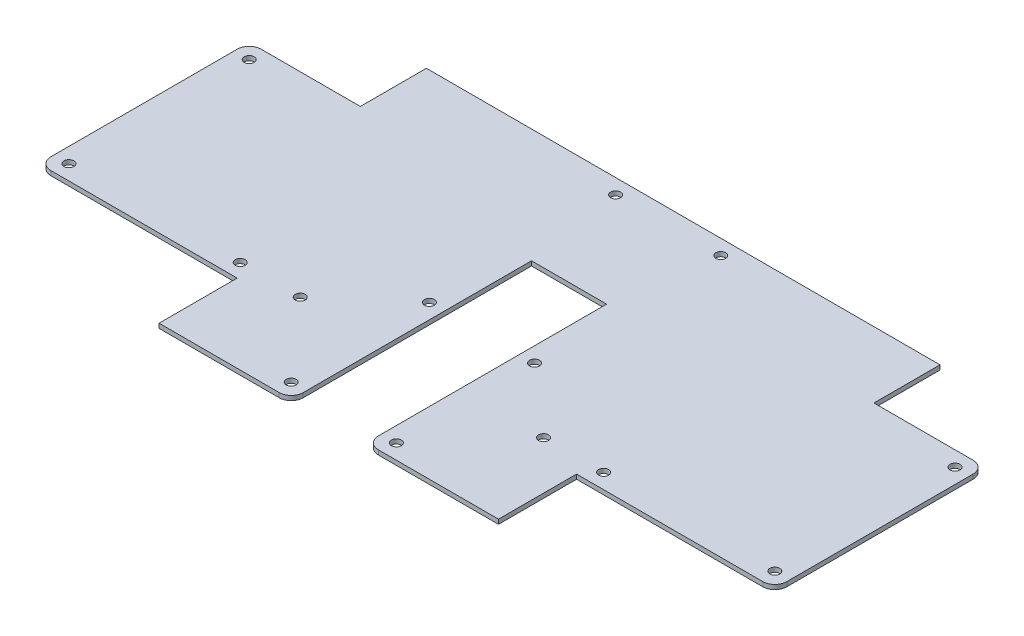
from build123d import *

# Parameters (mm, degrees)
SKETCH1_W           = 245
SKETCH1_H           = 118
BOSS_EXTRUDE1_DEPTH = 1.5
SKETCH2_W           = 37
SKETCH2_H           = 22
SKETCH2_W_2         = 66
SKETCH2_H_2         = 26
SKETCH2_W_3         = 25
SKETCH2_H_3         = 80
CUT_EXTRUDE1_DEPTH  = 2.5
SKETCH3_R           = 1.65
CUT_EXTRUDE2_DEPTH  = 10
FILLET1_R           = 4


with BuildPart() as part:
    # Sketch1 → Boss-Extrude1 (new body)
    with BuildSketch(Plane(origin=(0, 0, 0), x_dir=(1, 0, 0), z_dir=(0, 1, 0))):
        with Locations((122.5, 59)):
            Rectangle(SKETCH1_W, SKETCH1_H)
    extrude(amount=BOSS_EXTRUDE1_DEPTH)

    # Sketch2 → Cut-Extrude1 (cut, through all)
    with BuildSketch(Plane(origin=(0, 1.5, 0), x_dir=(1, 0, 0), z_dir=(0, 1, 0))):
        with Locations((18.5, 107)):
            Rectangle(SKETCH2_W, SKETCH2_H)
        with Locations((33, 13)):
            Rectangle(SKETCH2_W_2, SKETCH2_H_2)
        with Locations((226.5, 107)):
            Rectangle(SKETCH2_W, SKETCH2_H)
        with Locations((212, 13)):
            Rectangle(SKETCH2_W_2, SKETCH2_H_2)
        with Locations((122.5, 40)):
            Rectangle(SKETCH2_W_3, SKETCH2_H_3)
    extrude(amount=-CUT_EXTRUDE1_DEPTH, mode=Mode.SUBTRACT)

    # Sketch3 → Cut-Extrude2 (cut)
    with BuildSketch(Plane.XZ):
        with Locations((5, -31)):
            Circle(SKETCH3_R)
        with Locations((5, -91)):
            Circle(SKETCH3_R)
        with Locations((105, -5)):
            Circle(SKETCH3_R)
        with Locations((105, -51)):
            Circle(SKETCH3_R)
        with Locations((105, -113)):
            Circle(SKETCH3_R)
        with Locations((140, -51)):
            Circle(SKETCH3_R)
        with Locations((140, -5)):
            Circle(SKETCH3_R)
        with Locations((140, -113)):
            Circle(SKETCH3_R)
        with Locations((240, -31)):
            Circle(SKETCH3_R)
        with Locations((240, -91)):
            Circle(SKETCH3_R)
        with Locations((62, -31)):
            Circle(SKETCH3_R)
        with Locations((82, -31)):
            Circle(SKETCH3_R)
        with Locations((163, -31)):
            Circle(SKETCH3_R)
        with Locations((183, -31)):
            Circle(SKETCH3_R)
    extrude(amount=-CUT_EXTRUDE2_DEPTH, mode=Mode.SUBTRACT)

    # Fillet1
    fillet1_edges = [part.edges().sort_by_distance(p)[0] for p in [
        (0, 0.75, -26),
        (245, 0.75, -96),
        (245, 0.75, -26),
        (110, 0.75, 0),
        (135, 0.75, 0),
        (0, 0.75, -96),
    ]]
    fillet(fillet1_edges, radius=FILLET1_R)


solid = part.part
